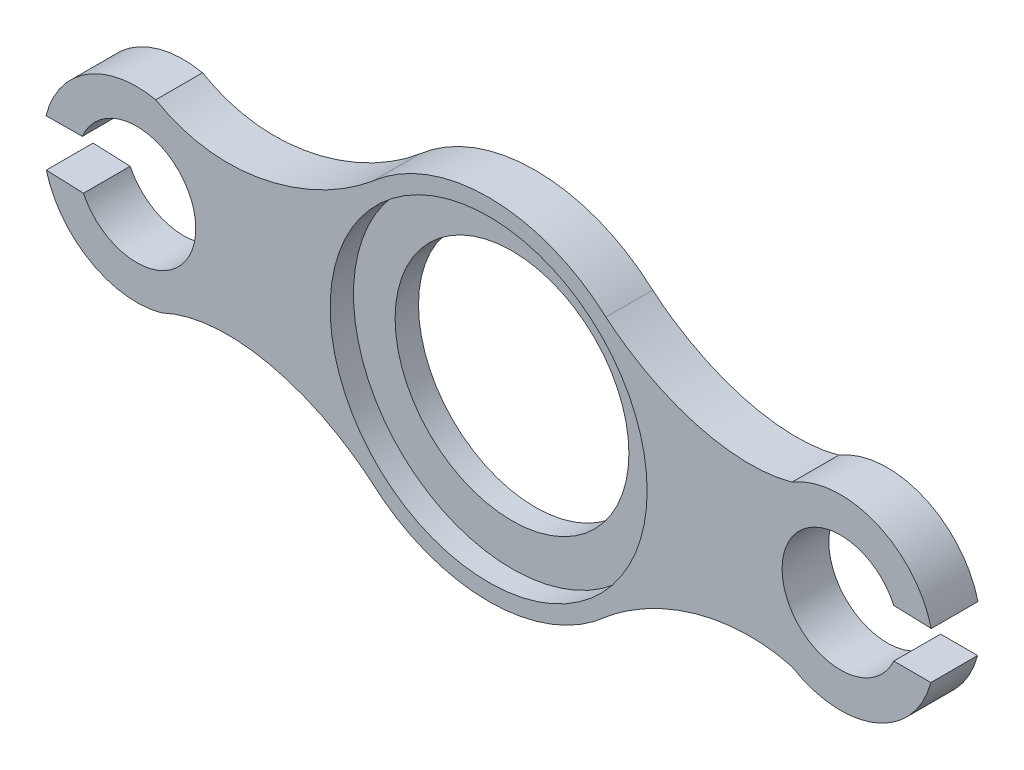
from build123d import *

# Parameters (mm, degrees)
SKETCH1_R            = 67.8
BOSS_EXTRUDE11_DEPTH = 20
SKETCH1_14_R         = 67.8
SKETCH1_14_R_2       = 50
BOSS_EXTRUDE12_DEPTH = 10


with BuildPart() as part:
    # Sketch1 → Boss-Extrude11 (new body)
    with BuildSketch(Plane.XY):
        with BuildLine():
            ThreePointArc((-142.34841847, 39.793144177), (-171.751198945, 34.54231297), (-189.319803444, 10.387833799))
            Line((-189.319803444, 10.387833799), (-173.788179779, 10.509033195))
            ThreePointArc((-173.788179779, 10.509033195), (-125.263414989, 1.225516677), (-173.304176626, -10.303650604))
            Line((-173.304176626, -10.303650604), (-189.176390414, -9.665625813))
            ThreePointArc((-189.176390414, -9.665625813), (-170.488139493, -34.024955882), (-140.039484135, -37.962857708))
            add(Edge.make_bspline(
                [(-140.039484135, -37.962857708), (-110.680407711, -24.08950974), (-74.045313114, -35.434332747), (-50.174260477, -55.547410213)],
                knots=[0.026307931, 0.026307931, 0.026307931, 0.026307931, 0.97051711, 0.97051711, 0.97051711, 0.97051711], degree=3))
            ThreePointArc((-50.174260477, -55.547410213), (0, -74.85299724), (50.174260477, -55.547410213))
            add(Edge.make_bspline(
                [(129.742096758, -34.176303824), (102.491508086, -26.790776239), (71.323341509, -37.727789453), (50.174260477, -55.547410213)],
                knots=[0.133974342, 0.133974342, 0.133974342, 0.133974342, 0.97051711, 0.97051711, 0.97051711, 0.97051711], degree=3))
            ThreePointArc((129.742096758, -34.176303824), (165.435107978, -37.117723558), (189.176390414, -10.303650604))
            Line((189.176390414, -10.303650604), (173.304176626, -10.303650604))
            ThreePointArc((173.304176626, -10.303650604), (125.526231498, 0), (173.304176626, 10.303650604))
            Line((173.304176626, 10.303650604), (189.319803444, 9.749809007))
            ThreePointArc((189.319803444, 9.749809007), (165.700168673, 37.010155777), (129.742096758, 34.176303824))
            add(Edge.make_bspline(
                [(129.742096758, 34.176303824), (102.491508086, 26.790776239), (71.323341509, 37.727789453), (50.174260477, 55.547410213)],
                knots=[0.133974342, 0.133974342, 0.133974342, 0.133974342, 0.97051711, 0.97051711, 0.97051711, 0.97051711], degree=3))
            ThreePointArc((50.174260477, 55.547410213), (0.430867535, 74.851757154), (-49.531464066, 56.121344098))
            add(Edge.make_bspline(
                [(-49.531464066, 56.121344098), (-73.874099433, 35.650364126), (-112.8184932, 22.464713449), (-142.34841847, 39.793144177)],
                knots=[0.14825783, 0.14825783, 0.14825783, 0.14825783, 1.127132671, 1.127132671, 1.127132671, 1.127132671], degree=3))
        make_face()
        Circle(SKETCH1_R, mode=Mode.SUBTRACT)
    extrude(amount=BOSS_EXTRUDE11_DEPTH)

    # Sketch1_14 → Boss-Extrude12 (add)
    with BuildSketch(Plane.XY):
        Circle(SKETCH1_14_R)
        Circle(SKETCH1_14_R_2, mode=Mode.SUBTRACT)
    extrude(amount=BOSS_EXTRUDE12_DEPTH)


solid = part.part
